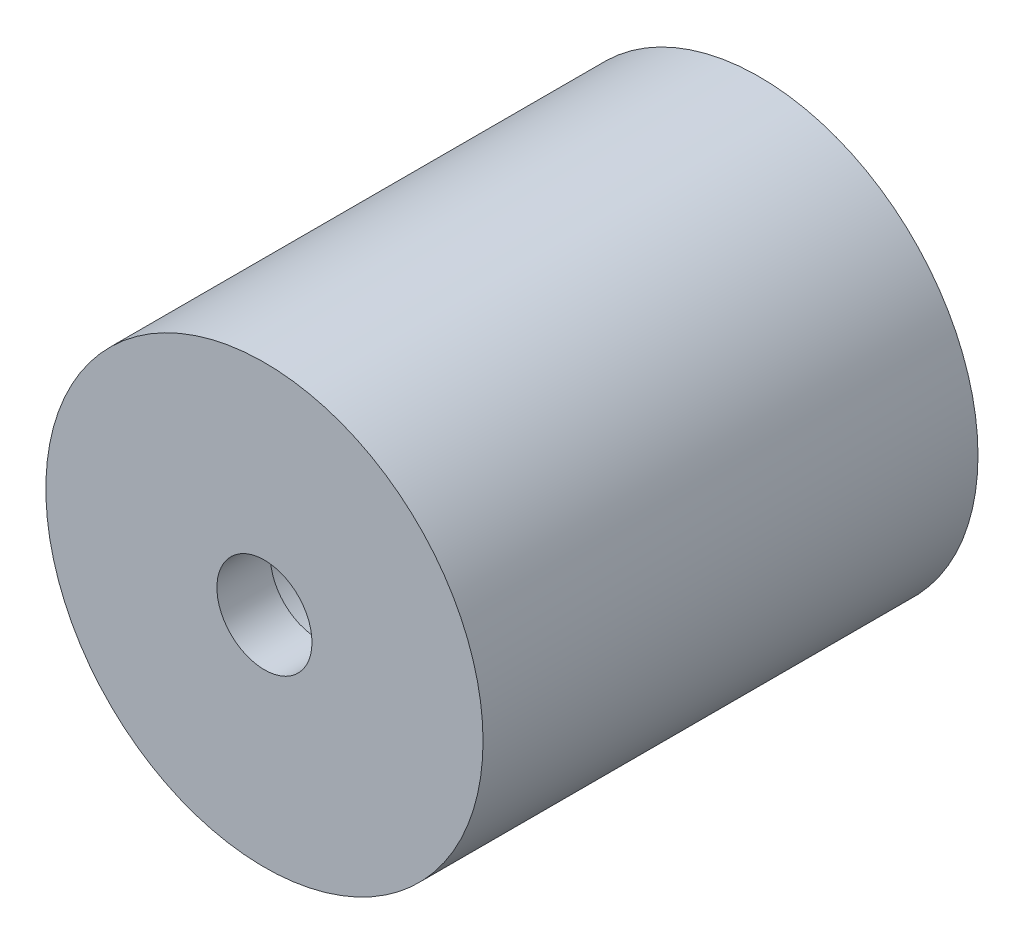
from build123d import *

# Parameters (mm, degrees)
SKETCH1_R           = 8.175
SKETCH1_R_2         = 1.778
BOSS_EXTRUDE1_DEPTH = 2
BOSS_EXTRUDE2_START = -16.51
SKETCH1_3_R         = 8.175
SKETCH1_3_R_2       = 3.175
BOSS_EXTRUDE2_DEPTH = 16.51


with BuildPart() as part:
    # Sketch1 → Boss-Extrude1 (new body)
    with BuildSketch(Plane.XY):
        Circle(SKETCH1_R)
        Circle(SKETCH1_R_2, mode=Mode.SUBTRACT)
    extrude(amount=BOSS_EXTRUDE1_DEPTH)

    # Sketch1_3 → Boss-Extrude2 (add)
    with BuildSketch(Plane.XY.offset(BOSS_EXTRUDE2_START)):
        Circle(SKETCH1_3_R)
        Circle(SKETCH1_3_R_2, mode=Mode.SUBTRACT)
    extrude(amount=BOSS_EXTRUDE2_DEPTH)


solid = part.part
